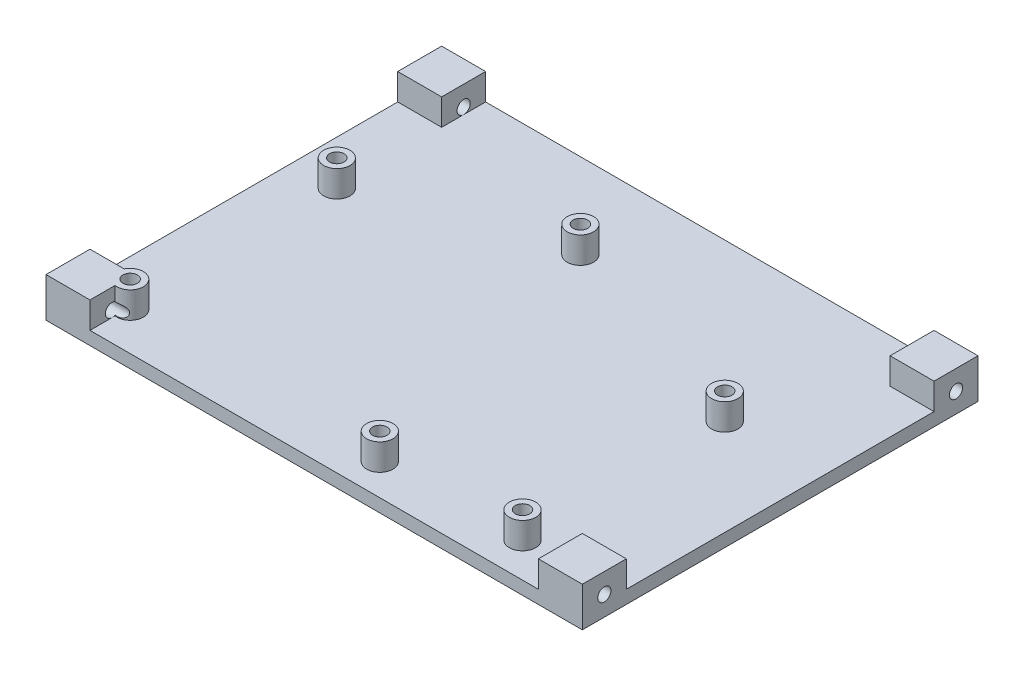
from build123d import *

# Parameters (mm, degrees)
SKETCH1_W           = 122
SKETCH1_H           = 90
BOSS_EXTRUDE1_DEPTH = 3
SKETCH2_R           = 3
SKETCH2_W           = 10
SKETCH2_H           = 10
BOSS_EXTRUDE2_DEPTH = 6
SKETCH3_R           = 1.65
CUT_EXTRUDE1_DEPTH  = 26
CUT_EXTRUDE2_REACH  = 124
SKETCH4_R           = 1.5
CUT_EXTRUDE3_REACH  = 124
SKETCH5_R           = 1.5


with BuildPart() as part:
    # Sketch1 → Boss-Extrude1 (new body)
    with BuildSketch(Plane(origin=(0, 0, 0), x_dir=(1, 0, 0), z_dir=(0, 1, 0))):
        with Locations((61, 45)):
            Rectangle(SKETCH1_W, SKETCH1_H)
    extrude(amount=BOSS_EXTRUDE1_DEPTH)

    # Sketch2 → Boss-Extrude2 (add)
    with BuildSketch(Plane(origin=(0, 3, 0), x_dir=(1, 0, 0), z_dir=(0, 1, 0))):
        with Locations((68.8138, 7.1202)):
            Circle(SKETCH2_R)
        with Locations((100.513, 7.8822)):
            Circle(SKETCH2_R)
        with Locations((10.089, 56.0656)):
            Circle(SKETCH2_R)
        with Locations((100.132, 54.2622)):
            Circle(SKETCH2_R)
        with Locations((50.856, 70.696)):
            Circle(SKETCH2_R)
        with BuildLine():
            Line((0, 0), (10, 0))
            Line((10, 0), (10, 5.706645394))
            ThreePointArc((10, 5.706645394), (13.135115844, 10.046973419), (7.781127404, 10))
            Line((7.781127404, 10), (0, 10))
            Line((0, 10), (0, 0))
        make_face()
        with Locations((5, 85)):
            Rectangle(SKETCH2_W, SKETCH2_H)
        with Locations((117, 85)):
            Rectangle(SKETCH2_W, SKETCH2_H)
        with Locations((117, 5)):
            Rectangle(SKETCH2_W, SKETCH2_H)
    extrude(amount=BOSS_EXTRUDE2_DEPTH)

    # Sketch3 → Cut-Extrude1 (cut)
    with BuildSketch(Plane(origin=(0, 9, 0), x_dir=(1, 0, 0), z_dir=(0, 1, 0))):
        with Locations((10.089, 56.0656)):
            Circle(SKETCH3_R)
        with Locations((50.856, 70.696)):
            Circle(SKETCH3_R)
        with Locations((100.132, 54.2622)):
            Circle(SKETCH3_R)
        with Locations((100.513, 7.8822)):
            Circle(SKETCH3_R)
        with Locations((68.8138, 7.1202)):
            Circle(SKETCH3_R)
        with Locations((10.47, 8.6696)):
            Circle(SKETCH3_R)
    extrude(amount=-CUT_EXTRUDE1_DEPTH, mode=Mode.SUBTRACT)

    # Sketch4 → Cut-Extrude2 (cut, up to next)
    with BuildSketch(Plane.ZY, mode=Mode.PRIVATE) as cut_extrude2_sk1:
        with Locations((-85, 4.5)):
            Circle(SKETCH4_R)
    cut_extrude2_tool1 = extrude(cut_extrude2_sk1.sketch, amount=-CUT_EXTRUDE2_REACH, mode=Mode.PRIVATE) & part.part
    add(cut_extrude2_tool1.solids().sort_by_distance((0, 4.5, -85))[0], mode=Mode.SUBTRACT)
    # Sketch4 → Cut-Extrude2 (cut, up to next)
    with BuildSketch(Plane.ZY, mode=Mode.PRIVATE) as cut_extrude2_sk2:
        with Locations((-5, 4.5)):
            Circle(SKETCH4_R)
    cut_extrude2_tool2 = extrude(cut_extrude2_sk2.sketch, amount=-CUT_EXTRUDE2_REACH, mode=Mode.PRIVATE) & part.part
    add(cut_extrude2_tool2.solids().sort_by_distance((0, 4.5, -5))[0], mode=Mode.SUBTRACT)

    # Sketch5 → Cut-Extrude3 (cut, up to next)
    with BuildSketch(Plane(origin=(122, 0, 0), x_dir=(0, 0, -1), z_dir=(1, 0, 0)), mode=Mode.PRIVATE) as cut_extrude3_sk1:
        with Locations((85, 4.5)):
            Circle(SKETCH5_R)
    cut_extrude3_tool1 = extrude(cut_extrude3_sk1.sketch, amount=-CUT_EXTRUDE3_REACH, mode=Mode.PRIVATE) & part.part
    add(cut_extrude3_tool1.solids().sort_by_distance((122, 4.5, -85))[0], mode=Mode.SUBTRACT)
    # Sketch5 → Cut-Extrude3 (cut, up to next)
    with BuildSketch(Plane(origin=(122, 0, 0), x_dir=(0, 0, -1), z_dir=(1, 0, 0)), mode=Mode.PRIVATE) as cut_extrude3_sk2:
        with Locations((5, 4.5)):
            Circle(SKETCH5_R)
    cut_extrude3_tool2 = extrude(cut_extrude3_sk2.sketch, amount=-CUT_EXTRUDE3_REACH, mode=Mode.PRIVATE) & part.part
    add(cut_extrude3_tool2.solids().sort_by_distance((122, 4.5, -5))[0], mode=Mode.SUBTRACT)


solid = part.part
